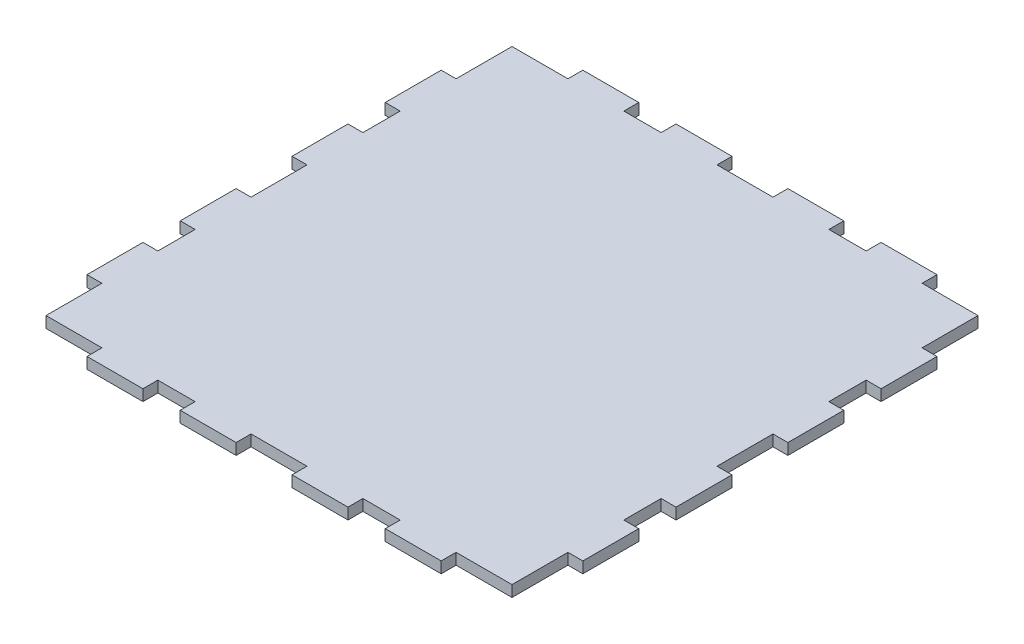
from build123d import *

# Parameters (mm, degrees)
BOSS_EXTRUDE1_DEPTH = 3
SKETCH2_R           = 25
SKETCH2_R_2         = 17.5
BOSS_EXTRUDE2_DEPTH = 10


with BuildPart() as part:
    # Sketch1 → Boss-Extrude1 (new body)
    with BuildSketch(Plane(origin=(0, 0, 0), x_dir=(1, 0, 0), z_dir=(0, 1, 0))):
        Polygon((7.5, -62.5), (7.5, -66.5), (22.5, -66.5), (22.5, -62.5), (32.5, -62.5), (32.5, -66.5), (47.5, -66.5), (47.5, -62.5), (57.5, -62.5), (62.5, -62.5), (62.5, -59), (62.5, -47.5), (66.5, -47.5), (66.5, -32.5), (62.5, -32.5), (62.5, -22.5), (66.5, -22.5), (66.5, -7.5), (62.5, -7.5), (62.5, 7.5), (66.5, 7.5), (66.5, 22.5), (62.5, 22.5), (62.5, 32.5), (66.5, 32.5), (66.5, 47.5), (62.5, 47.5), (62.5, 59), (62.5, 62.5), (57.5, 62.5), (47.5, 62.5), (47.5, 66.5), (32.5, 66.5), (32.5, 62.5), (22.5, 62.5), (22.5, 66.5), (7.5, 66.5), (7.5, 62.5), (-7.5, 62.5), (-7.5, 66.5), (-22.5, 66.5), (-22.5, 62.5), (-32.5, 62.5), (-32.5, 66.5), (-47.5, 66.5), (-47.5, 62.5), (-59, 62.5), (-62.5, 62.5), (-62.5, 59), (-62.5, 47.5), (-66.5, 47.5), (-66.5, 32.5), (-62.5, 32.5), (-62.5, 22.5), (-66.5, 22.5), (-66.5, 7.5), (-62.5, 7.5), (-62.5, -7.5), (-66.5, -7.5), (-66.5, -22.5), (-62.5, -22.5), (-62.5, -32.5), (-66.5, -32.5), (-66.5, -47.5), (-62.5, -47.5), (-62.5, -59), (-62.5, -62.5), (-59, -62.5), (-47.5, -62.5), (-47.5, -66.5), (-32.5, -66.5), (-32.5, -62.5), (-22.5, -62.5), (-22.5, -66.5), (-7.5, -66.5), (-7.5, -62.5), align=None)
    extrude(amount=BOSS_EXTRUDE1_DEPTH)

    # Sketch2 → Boss-Extrude2 (add)
    with BuildSketch(Plane.XZ):
        Circle(SKETCH2_R)
        Circle(SKETCH2_R_2, mode=Mode.SUBTRACT)
    extrude(amount=BOSS_EXTRUDE2_DEPTH)


solid = part.part
